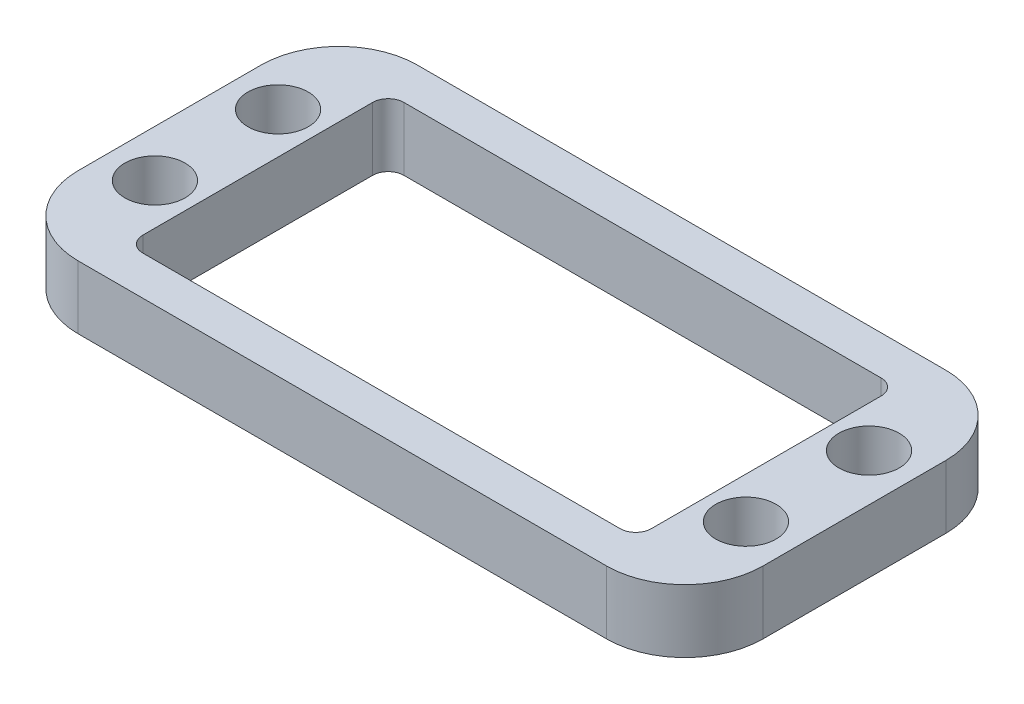
from build123d import *

# Parameters (mm, degrees)
SKETCH1_W                  = 55.620000012
SKETCH1_H                  = 27.550000018
SKETCH1_W_2                = 41.29999995
SKETCH1_H_2                = 21.200000018
BOSS_EXTRUDE1_DEPTH        = 5.1308
F_4_9_4_9_DIAMETER_HOLE1_D = 4.9
FILLET1_R                  = 6.35
FILLET2_R                  = 1.27


with BuildPart() as part:
    # Sketch1 → Boss-Extrude1 (new body)
    with BuildSketch(Plane(origin=(0, 0, 0), x_dir=(1, 0, 0), z_dir=(0, 1, 0))):
        Rectangle(SKETCH1_W, SKETCH1_H)
        Rectangle(SKETCH1_W_2, SKETCH1_H_2, mode=Mode.SUBTRACT)
    extrude(amount=BOSS_EXTRUDE1_DEPTH)

    # Ø4.9 (4.9) Diameter Hole1 (through all)
    with Locations(Plane(origin=(0, 5.1308, 0), x_dir=(1, 0, 0), z_dir=(0, 1, 0))):
        with Locations((24, -5), (-24, 5), (-24, -5), (24, 5)):
            Hole(F_4_9_4_9_DIAMETER_HOLE1_D / 2)

    # Fillet1
    fillet1_edges = [part.edges().sort_by_distance(p)[0] for p in [
        (27.810000006, 2.5654, 13.775000009),
        (-27.810000006, 2.5654, 13.775000009),
        (-27.810000006, 2.5654, -13.775000009),
        (27.810000006, 2.5654, -13.775000009),
    ]]
    fillet(fillet1_edges, radius=FILLET1_R)

    # Fillet2
    fillet2_edges = [part.edges().sort_by_distance(p)[0] for p in [
        (20.649999975, 2.5654, 10.600000009),
        (20.649999975, 2.5654, -10.600000009),
        (-20.649999975, 2.5654, -10.600000009),
        (-20.649999975, 2.5654, 10.600000009),
    ]]
    fillet(fillet2_edges, radius=FILLET2_R)


solid = part.part
